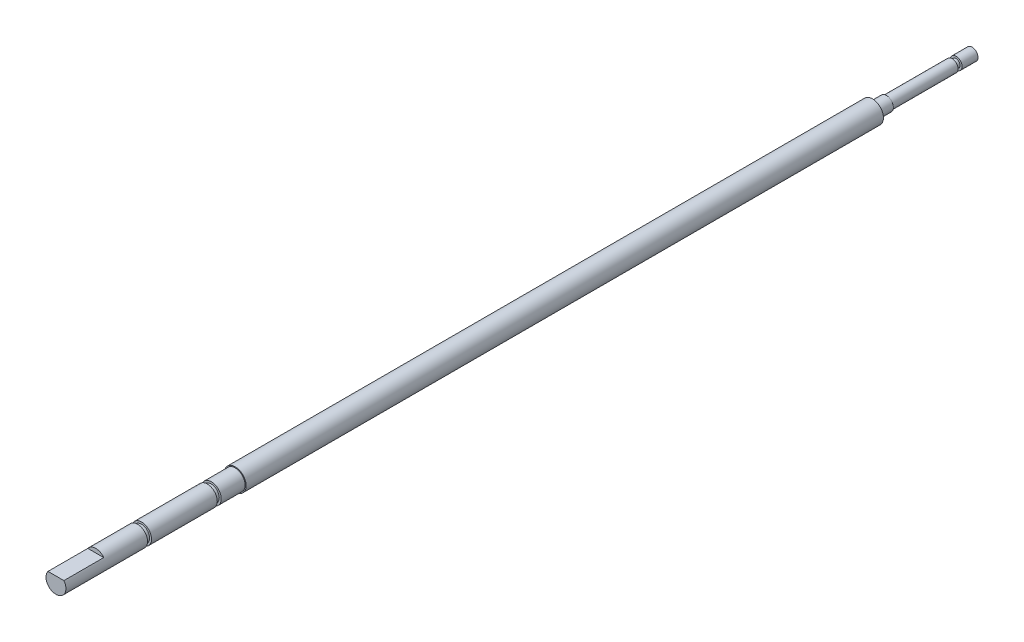
from build123d import *

# Parameters (mm, degrees)
SKETCH_1_R           = 2.75
EXTRUDE_6_DEPTH      = 250
SKETCH_22_R          = 3.543321461
SKETCH_22_R_2        = 1.75
CUT_EXTRUDE_16_DEPTH = 25
SKETCH_23_R          = 4.906655543
SKETCH_23_R_2        = 2.5
CUT_EXTRUDE_17_DEPTH = 61
SKETCH_29_R          = 7.224487221
CUT_EXTRUDE_18_DEPTH = 10
CUT_EXTRUDE_19_DEPTH = 20
SKETCH_33_R          = 3.493195313
SKETCH_33_R_2        = 2.5
CUT_EXTRUDE_20_DEPTH = 5
SKETCH_34_R          = 3.783708721
SKETCH_34_R_2        = 1.5
CUT_EXTRUDE_21_DEPTH = 21.5
SKETCH_36_R          = 3.547380577
SKETCH_36_R_2        = 1
CUT_EXTRUDE_22_DEPTH = 1
SKETCH_37_R          = 5.022204732
SKETCH_37_R_2        = 2
CUT_EXTRUDE_23_DEPTH = 1
SKETCH_38_R          = 5.160137664
SKETCH_38_R_2        = 2
CUT_EXTRUDE_24_DEPTH = 1
SKETCH_39_R          = 4.465898571
CUT_EXTRUDE_25_DEPTH = 10


with BuildPart() as part:
    # 草图1 → 凸台-拉伸6 (new body)
    with BuildSketch(Plane.XY):
        Circle(SKETCH_1_R)
    extrude(amount=EXTRUDE_6_DEPTH)

    # 草图22 → 切除-拉伸16 (cut)
    with BuildSketch(Plane(origin=(0, 0, 0), x_dir=(-1, 0, 0), z_dir=(0, 0, -1))):
        Circle(SKETCH_22_R)
        Circle(SKETCH_22_R_2, mode=Mode.SUBTRACT)
    extrude(amount=-CUT_EXTRUDE_16_DEPTH, mode=Mode.SUBTRACT)

    # 草图23 → 切除-拉伸17 (cut, through all)
    with BuildSketch(Plane(origin=(0, 0, 190), x_dir=(-1, 0, 0), z_dir=(0, 0, -1))):
        Circle(SKETCH_23_R)
        Circle(SKETCH_23_R_2, mode=Mode.SUBTRACT)
    extrude(amount=-CUT_EXTRUDE_17_DEPTH, mode=Mode.SUBTRACT)

    # 草图29 → 切除-拉伸18 (cut)
    with BuildSketch(Plane.XY.offset(250)):
        Circle(SKETCH_29_R)
    extrude(amount=-CUT_EXTRUDE_18_DEPTH, mode=Mode.SUBTRACT)

    # 草图32 → 切除-拉伸19 (cut)
    with BuildSketch(Plane.XY.offset(240)):
        with BuildLine():
            Line((-2, 1.5), (2, 1.5))
            ThreePointArc((2, 1.5), (0, 2.5), (-2, 1.5))
        make_face()
    extrude(amount=-CUT_EXTRUDE_19_DEPTH, mode=Mode.SUBTRACT)

    # 草图33 → 切除-拉伸20 (cut)
    with BuildSketch(Plane.XY.offset(190)):
        Circle(SKETCH_33_R)
        Circle(SKETCH_33_R_2, mode=Mode.SUBTRACT)
    extrude(amount=-CUT_EXTRUDE_20_DEPTH, mode=Mode.SUBTRACT)

    # 草图34 → 切除-拉伸21 (cut)
    with BuildSketch(Plane(origin=(0, 0, 0), x_dir=(-1, 0, 0), z_dir=(0, 0, -1))):
        Circle(SKETCH_34_R)
        Circle(SKETCH_34_R_2, mode=Mode.SUBTRACT)
    extrude(amount=-CUT_EXTRUDE_21_DEPTH, mode=Mode.SUBTRACT)

    # 草图36 → 切除-拉伸22 (cut)
    with BuildSketch(Plane(origin=(0, 0, 5), x_dir=(-1, 0, 0), z_dir=(0, 0, -1))):
        Circle(SKETCH_36_R)
        Circle(SKETCH_36_R_2, mode=Mode.SUBTRACT)
    extrude(amount=CUT_EXTRUDE_22_DEPTH, mode=Mode.SUBTRACT)

    # 草图37 → 切除-拉伸23 (cut)
    with BuildSketch(Plane.XY.offset(191)):
        Circle(SKETCH_37_R)
        Circle(SKETCH_37_R_2, mode=Mode.SUBTRACT)
    extrude(amount=CUT_EXTRUDE_23_DEPTH, mode=Mode.SUBTRACT)

    # 草图38 → 切除-拉伸24 (cut)
    with BuildSketch(Plane.XY.offset(208.5)):
        Circle(SKETCH_38_R)
        Circle(SKETCH_38_R_2, mode=Mode.SUBTRACT)
    extrude(amount=CUT_EXTRUDE_24_DEPTH, mode=Mode.SUBTRACT)

    # 草图39 → 切除-拉伸25 (cut)
    with BuildSketch(Plane.XY.offset(240)):
        Circle(SKETCH_39_R)
    extrude(amount=-CUT_EXTRUDE_25_DEPTH, mode=Mode.SUBTRACT)


solid = part.part
